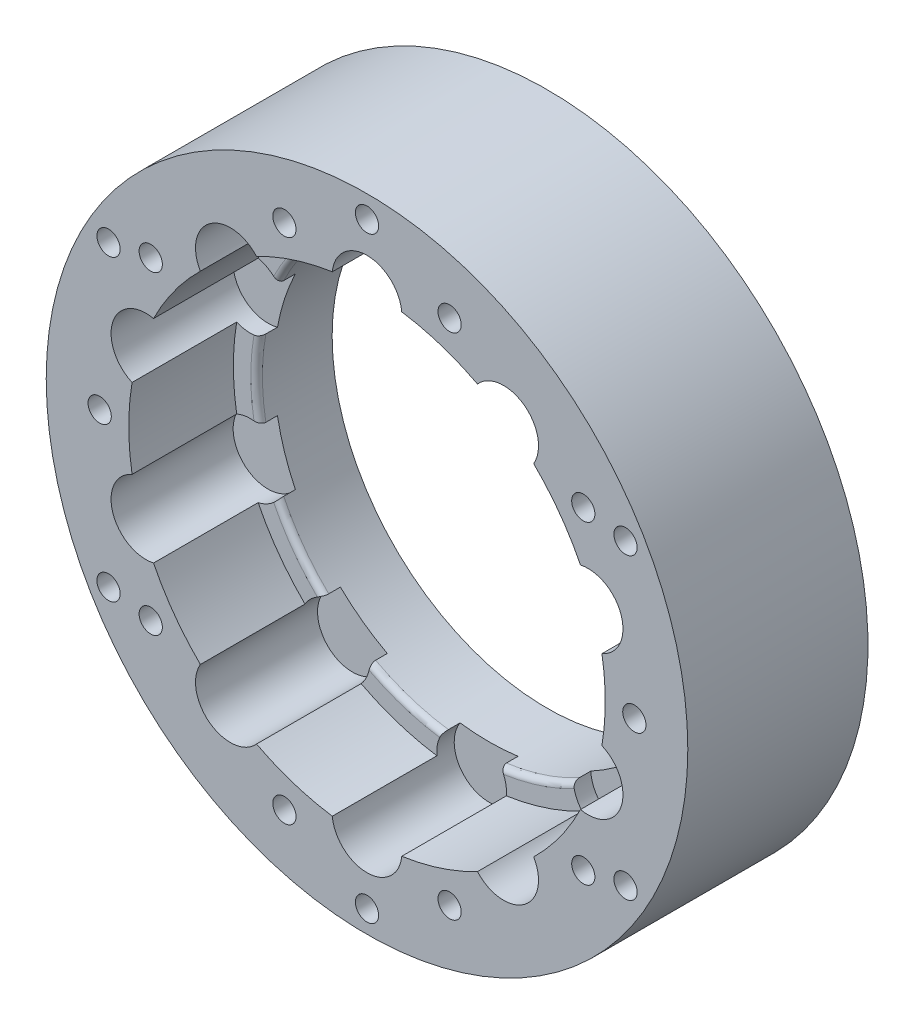
from build123d import *

# Parameters (mm, degrees)
SKETCH_1_R                = 27.6
EXTRUDE_1_DEPTH           = 9
SKETCH_2_R                = 27.6
EXTRUDE_2_DEPTH           = 3.5
SKETCH_3_R                = 3
CUT_EXTRUDE_1_DEPTH       = 1.5
SKETCH_4_R                = 1
CUT_EXTRUDE_2_DEPTH       = 1
CUT_EXTRUDE_2_DEPTH_BACK  = 13.5
SKETCH_7_R                = 18.5
CUT_EXTRUDE_4_DEPTH       = 12.5
SKETCH_9_R                = 18.5
CUT_EXTRUDE_6_DEPTH       = 11.5
SKETCH_10_R               = 27.6
SKETCH_10_R_2             = 1
SKETCH_10_R_3             = 18.5
EXTRUDE_4_DEPTH           = 2
SKETCH_11_R               = 1
EXTRUDE_5_DEPTH           = 14.5
SKETCH_12_R               = 27.6
SKETCH_12_R_2             = 18.5
EXTRUDE_6_DEPTH           = 1
SKETCH_13_R               = 1
CUT_EXTRUDE_8_DEPTH       = 1
CUT_EXTRUDE_8_DEPTH_BACK  = 16.5
SKETCH_14_R               = 1
CUT_EXTRUDE_9_DEPTH       = 6
FILLET_1_R                = 0.5
SKETCH_15_R               = 1
CUT_EXTRUDE_10_DEPTH      = 1
CUT_EXTRUDE_10_DEPTH_BACK = 16.5
CUT_EXTRUDE_11_DEPTH      = 2.5
SKETCH_17_R               = 20.5
CUT_EXTRUDE_12_DEPTH      = 9


with BuildPart() as part:
    # 草图1 → 凸台-拉伸1 (new body)
    with BuildSketch(Plane.XY):
        Circle(SKETCH_1_R)
        with BuildLine():
            ThreePointArc((2.991550601, 19.775), (0, 23), (-2.991550601, 19.775))
            ThreePointArc((-2.991550601, 19.775), (-6.180339887, 19.021130326), (-9.203238088, 17.756700389))
            ThreePointArc((-9.203238088, 17.756700389), (-13.519060803, 18.607390871), (-14.04366864, 14.239921739))
            ThreePointArc((-14.04366864, 14.239921739), (-16.180339887, 11.755705046), (-17.882702634, 8.955944757))
            ThreePointArc((-17.882702634, 8.955944757), (-21.874299875, 7.107390871), (-19.731582585, 3.265677371))
            ThreePointArc((-19.731582585, 3.265677371), (-20, 0), (-19.731582585, -3.265677371))
            ThreePointArc((-19.731582585, -3.265677371), (-21.874299875, -7.107390871), (-17.882702634, -8.955944757))
            ThreePointArc((-17.882702634, -8.955944757), (-16.180339887, -11.755705046), (-14.04366864, -14.239921739))
            ThreePointArc((-14.04366864, -14.239921739), (-13.519060803, -18.607390871), (-9.203238088, -17.756700389))
            ThreePointArc((-9.203238088, -17.756700389), (-6.180339887, -19.021130326), (-2.991550601, -19.775))
            ThreePointArc((-2.991550601, -19.775), (0, -23), (2.991550601, -19.775))
            ThreePointArc((2.991550601, -19.775), (6.180339887, -19.021130326), (9.203238088, -17.756700389))
            ThreePointArc((9.203238088, -17.756700389), (13.519060803, -18.607390871), (14.04366864, -14.239921739))
            ThreePointArc((14.04366864, -14.239921739), (16.180339887, -11.755705046), (17.882702634, -8.955944757))
            ThreePointArc((17.882702634, -8.955944757), (21.874299875, -7.107390871), (19.731582585, -3.265677371))
            ThreePointArc((19.731582585, -3.265677371), (20, 0), (19.731582585, 3.265677371))
            ThreePointArc((19.731582585, 3.265677371), (21.874299875, 7.107390871), (17.882702634, 8.955944757))
            ThreePointArc((17.882702634, 8.955944757), (16.180339887, 11.755705046), (14.04366864, 14.239921739))
            ThreePointArc((14.04366864, 14.239921739), (13.519060803, 18.607390871), (9.203238088, 17.756700389))
            ThreePointArc((9.203238088, 17.756700389), (6.180339887, 19.021130326), (2.991550601, 19.775))
        make_face(mode=Mode.SUBTRACT)
    extrude(amount=EXTRUDE_1_DEPTH)

    # 草图2 → 凸台-拉伸2 (add)
    with BuildSketch(Plane(origin=(0, 0, 0), x_dir=(-1, 0, 0), z_dir=(0, 0, -1))):
        Circle(SKETCH_2_R)
    extrude(amount=EXTRUDE_2_DEPTH)

    # 草图3 → 切除-拉伸1 (cut)
    with BuildSketch(Plane.XY):
        with Locations((0, 20)):
            Circle(SKETCH_3_R)
        with Locations((11.755705046, 16.180339888)):
            Circle(SKETCH_3_R)
        with Locations((19.021130326, 6.180339888)):
            Circle(SKETCH_3_R)
        with Locations((19.021130326, -6.180339887)):
            Circle(SKETCH_3_R)
        with Locations((11.755705046, -16.180339887)):
            Circle(SKETCH_3_R)
        with Locations((0, -20)):
            Circle(SKETCH_3_R)
        with Locations((-11.755705046, -16.180339888)):
            Circle(SKETCH_3_R)
        with Locations((-19.021130326, -6.180339888)):
            Circle(SKETCH_3_R)
        with Locations((-19.021130326, 6.180339887)):
            Circle(SKETCH_3_R)
        with Locations((-11.755705046, 16.180339887)):
            Circle(SKETCH_3_R)
    extrude(amount=-CUT_EXTRUDE_1_DEPTH, mode=Mode.SUBTRACT)

    # 草图4 → 切除-拉伸2 (cut, two sides)
    with BuildSketch(Plane.XY.offset(9)) as cut_extrude_2_sk:
        with Locations((7.935556416, 24.423131338)):
            Circle(SKETCH_4_R)
        with Locations((20.775556416, 15.094325279)):
            Circle(SKETCH_4_R)
        with Locations((25.68, 0)):
            Circle(SKETCH_4_R)
        with Locations((20.775556416, -15.094325279)):
            Circle(SKETCH_4_R)
        with Locations((7.935556416, -24.423131338)):
            Circle(SKETCH_4_R)
        with Locations((-7.935556416, -24.423131338)):
            Circle(SKETCH_4_R)
        with Locations((-20.775556416, -15.094325279)):
            Circle(SKETCH_4_R)
        with Locations((-25.68, 0)):
            Circle(SKETCH_4_R)
        with Locations((-20.775556416, 15.094325279)):
            Circle(SKETCH_4_R)
        with Locations((-7.935556416, 24.423131338)):
            Circle(SKETCH_4_R)
    extrude(amount=CUT_EXTRUDE_2_DEPTH, mode=Mode.SUBTRACT)
    extrude(cut_extrude_2_sk.sketch, amount=-CUT_EXTRUDE_2_DEPTH_BACK, mode=Mode.SUBTRACT)

    # 草图7 → 切除-拉伸4 (cut)
    with BuildSketch(Plane.XY.offset(-1.5)):
        Circle(SKETCH_7_R)
    extrude(amount=-CUT_EXTRUDE_4_DEPTH, mode=Mode.SUBTRACT)

    # 草图9 → 切除-拉伸6 (cut, through all)
    with BuildSketch(Plane(origin=(0, 0, -1.5), x_dir=(-1, 0, 0), z_dir=(0, 0, -1))):
        Circle(SKETCH_9_R)
    extrude(amount=-CUT_EXTRUDE_6_DEPTH, mode=Mode.SUBTRACT)

    # 草图10 → 凸台-拉伸4 (add)
    with BuildSketch(Plane(origin=(0, 0, -3.5), x_dir=(-1, 0, 0), z_dir=(0, 0, -1))):
        Circle(SKETCH_10_R)
        with Locations((-7.935556416, 24.423131338)):
            Circle(SKETCH_10_R_2, mode=Mode.SUBTRACT)
        with Locations((7.935556416, 24.423131338)):
            Circle(SKETCH_10_R_2, mode=Mode.SUBTRACT)
        with Locations((20.775556416, 15.094325279)):
            Circle(SKETCH_10_R_2, mode=Mode.SUBTRACT)
        with Locations((25.68, 0)):
            Circle(SKETCH_10_R_2, mode=Mode.SUBTRACT)
        with Locations((20.775556416, -15.094325279)):
            Circle(SKETCH_10_R_2, mode=Mode.SUBTRACT)
        with Locations((7.935556416, -24.423131338)):
            Circle(SKETCH_10_R_2, mode=Mode.SUBTRACT)
        with Locations((-7.935556416, -24.423131338)):
            Circle(SKETCH_10_R_2, mode=Mode.SUBTRACT)
        with Locations((-20.775556416, -15.094325279)):
            Circle(SKETCH_10_R_2, mode=Mode.SUBTRACT)
        with Locations((-25.68, 0)):
            Circle(SKETCH_10_R_2, mode=Mode.SUBTRACT)
        with Locations((-20.775556416, 15.094325279)):
            Circle(SKETCH_10_R_2, mode=Mode.SUBTRACT)
        Circle(SKETCH_10_R_3, mode=Mode.SUBTRACT)
    extrude(amount=EXTRUDE_4_DEPTH)

    # 草图11 → 凸台-拉伸5 (add)
    with BuildSketch(Plane(origin=(0, 0, -5.5), x_dir=(-1, 0, 0), z_dir=(0, 0, -1))):
        with Locations((-7.935556416, 24.423131338)):
            Circle(SKETCH_11_R)
        with Locations((7.935556416, 24.423131338)):
            Circle(SKETCH_11_R)
        with Locations((20.775556416, 15.094325279)):
            Circle(SKETCH_11_R)
        with Locations((25.68, 0)):
            Circle(SKETCH_11_R)
        with Locations((20.775556416, -15.094325279)):
            Circle(SKETCH_11_R)
        with Locations((7.935556416, -24.423131338)):
            Circle(SKETCH_11_R)
        with Locations((-7.935556416, -24.423131338)):
            Circle(SKETCH_11_R)
        with Locations((-20.775556416, -15.094325279)):
            Circle(SKETCH_11_R)
        with Locations((-25.68, 0)):
            Circle(SKETCH_11_R)
        with Locations((-20.775556416, 15.094325279)):
            Circle(SKETCH_11_R)
    extrude(amount=-EXTRUDE_5_DEPTH)

    # 草图12 → 凸台-拉伸6 (add)
    with BuildSketch(Plane(origin=(0, 0, -5.5), x_dir=(-1, 0, 0), z_dir=(0, 0, -1))):
        Circle(SKETCH_12_R)
        Circle(SKETCH_12_R_2, mode=Mode.SUBTRACT)
    extrude(amount=EXTRUDE_6_DEPTH)

    # 草图13 → 切除-拉伸8 (cut, two sides)
    with BuildSketch(Plane.XY.offset(9)) as cut_extrude_8_sk:
        with Locations((0, 25.68)):
            Circle(SKETCH_13_R)
        with Locations((22.239532369, 12.84)):
            Circle(SKETCH_13_R)
        with Locations((22.239532369, -12.84)):
            Circle(SKETCH_13_R)
        with Locations((0, -25.68)):
            Circle(SKETCH_13_R)
        with Locations((-22.239532369, -12.84)):
            Circle(SKETCH_13_R)
        with Locations((-22.239532369, 12.84)):
            Circle(SKETCH_13_R)
    extrude(amount=CUT_EXTRUDE_8_DEPTH, mode=Mode.SUBTRACT)
    extrude(cut_extrude_8_sk.sketch, amount=-CUT_EXTRUDE_8_DEPTH_BACK, mode=Mode.SUBTRACT)

    # 草图14 → 切除-拉伸9 (cut)
    with BuildSketch(Plane.XY.offset(9)):
        with Locations((7.107390871, 21.874299875)):
            Circle(SKETCH_14_R)
        with Locations((23, 0)):
            Circle(SKETCH_14_R)
        with Locations((7.107390871, -21.874299875)):
            Circle(SKETCH_14_R)
        with Locations((-18.607390871, -13.519060803)):
            Circle(SKETCH_14_R)
        with Locations((-18.607390871, 13.519060803)):
            Circle(SKETCH_14_R)
    extrude(amount=-CUT_EXTRUDE_9_DEPTH, mode=Mode.SUBTRACT)

    # 圆角1
    fillet_1_edges = [part.edges().sort_by_distance(p)[0] for p in [
        (-14.966814396, 10.874027167, 0),
        (-18.425963866, -1.653437516, 0),
        (-14.966814396, -10.874027167, 0),
        (-5.716814396, -17.594545551, 0),
        (5.716814396, -17.594545551, 0),
        (14.966814396, -10.874027167, 0),
        (18.5, 0, 0),
        (14.966814396, 10.874027167, 0),
        (-5.716814396, 17.594545551, 0),
        (5.716814396, 17.594545551, 0),
    ]]
    fillet(fillet_1_edges, radius=FILLET_1_R)

    # 草图15 → 切除-拉伸10 (cut, two sides)
    with BuildSketch(Plane.XY.offset(9)) as cut_extrude_10_sk:
        with Locations((-7.107390871, 21.874299875)):
            Circle(SKETCH_15_R)
        with Locations((18.607390871, 13.519060803)):
            Circle(SKETCH_15_R)
        with Locations((18.607390871, -13.519060803)):
            Circle(SKETCH_15_R)
        with Locations((-7.107390871, -21.874299875)):
            Circle(SKETCH_15_R)
        with Locations((-23, 0)):
            Circle(SKETCH_15_R)
    extrude(amount=CUT_EXTRUDE_10_DEPTH, mode=Mode.SUBTRACT)
    extrude(cut_extrude_10_sk.sketch, amount=-CUT_EXTRUDE_10_DEPTH_BACK, mode=Mode.SUBTRACT)

    # 草图16 → 切除-拉伸11 (cut)
    with BuildSketch(Plane(origin=(0, 0, -6.5), x_dir=(-1, 0, 0), z_dir=(0, 0, -1))):
        Polygon((5.113734803, 22.917293395), (7.013821721, 24.122353436), (9.007477789, 23.079359916), (9.101046939, 20.831306355), (7.107390871, 19.624299875), (5.207303952, 20.669239834), align=None)
        Polygon((21.266760647, 1.434706013), (23.375872178, 2.218382317), (25.109111531, 0.783676304), (24.733239353, -1.434706013), (22.624127822, -2.218382317), (20.860122838, -0.695288237), align=None)
        Polygon((7.936276958, -19.782542754), (9.33334872, -21.546257723), (8.504462633, -23.638014844), (6.278504783, -23.966056996), (4.881433021, -22.202342027), (5.784874053, -20.054011637), align=None)
        Polygon((-16.361871743, -13.660989819), (-17.60754544, -15.53470192), (-19.853064568, -15.392772904), (-20.852909999, -13.377131787), (-19.607236301, -11.503419685), (-17.284874053, -11.698772565), align=None)
        Polygon((-18.048469814, 11.339586726), (-20.21541026, 11.945283931), (-20.774331316, 14.124758008), (-19.166311927, 15.69853488), (-16.999371481, 15.092837675), (-16.467513709, 12.823772565), align=None)
    extrude(amount=-CUT_EXTRUDE_11_DEPTH, mode=Mode.SUBTRACT)

    # 草图17 → 切除-拉伸12 (cut)
    with BuildSketch(Plane.XY.offset(9)):
        Circle(SKETCH_17_R)
    extrude(amount=-CUT_EXTRUDE_12_DEPTH, mode=Mode.SUBTRACT)


solid = part.part
